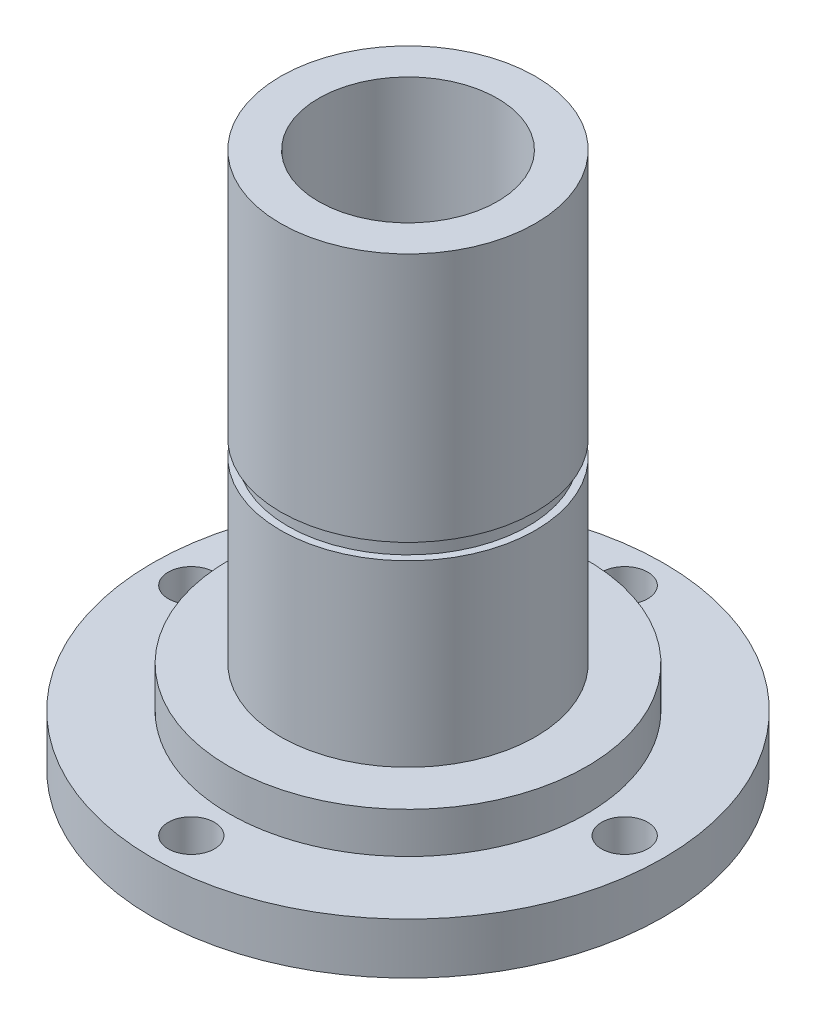
from build123d import *

# Parameters (mm, degrees)
SKETCH1_R           = 11.1125
SKETCH1_R_2         = 5.55625
BOSS_EXTRUDE1_DEPTH = 5.715
SKETCH2_R           = 7.91845
SKETCH2_R_2         = 5.55625
BOSS_EXTRUDE2_DEPTH = 27.6225
SKETCH3_OUTSIDE_W   = 33.388
SKETCH3_OUTSIDE_H   = 33.388
SKETCH3_OUTSIDE_R   = 7.4676
CUT_EXTRUDE1_DEPTH  = 0.9906
SKETCH4_R           = 15.875
SKETCH4_R_2         = 1.4351
SKETCH4_R_3         = 11.1125
BOSS_EXTRUDE3_DEPTH = 3.175


with BuildPart() as part:
    # Sketch1 → Boss-Extrude1 (new body)
    with BuildSketch(Plane(origin=(0, 0, 0), x_dir=(1, 0, 0), z_dir=(0, 1, 0))):
        Circle(SKETCH1_R)
        Circle(SKETCH1_R_2, mode=Mode.SUBTRACT)
    extrude(amount=BOSS_EXTRUDE1_DEPTH)

    # Sketch2 → Boss-Extrude2 (add)
    with BuildSketch(Plane(origin=(0, 5.715, 0), x_dir=(1, 0, 0), z_dir=(0, 1, 0))):
        Circle(SKETCH2_R)
        Circle(SKETCH2_R_2, mode=Mode.SUBTRACT)
    extrude(amount=BOSS_EXTRUDE2_DEPTH)

    # Sketch3 outside → Cut-Extrude1 (cut)
    with BuildSketch(Plane(origin=(0, 16.8275, 0), x_dir=(-1, 0, 0), z_dir=(0, 1, 0))):
        Rectangle(SKETCH3_OUTSIDE_W, SKETCH3_OUTSIDE_H)
        Circle(SKETCH3_OUTSIDE_R, mode=Mode.SUBTRACT)
    extrude(amount=CUT_EXTRUDE1_DEPTH, mode=Mode.SUBTRACT)


with BuildPart() as body_2:
    # Sketch4 → Boss-Extrude3 (new body)
    with BuildSketch(Plane.XZ):
        Circle(SKETCH4_R)
        with Locations((0, 13.462)):
            Circle(SKETCH4_R_2, mode=Mode.SUBTRACT)
        with Locations((13.462, 0)):
            Circle(SKETCH4_R_2, mode=Mode.SUBTRACT)
        with Locations((0, -13.462)):
            Circle(SKETCH4_R_2, mode=Mode.SUBTRACT)
        with Locations((-13.462, 0)):
            Circle(SKETCH4_R_2, mode=Mode.SUBTRACT)
        Circle(SKETCH4_R_3, mode=Mode.SUBTRACT)
    extrude(amount=-BOSS_EXTRUDE3_DEPTH)


solid = Compound([part.part, body_2.part])
